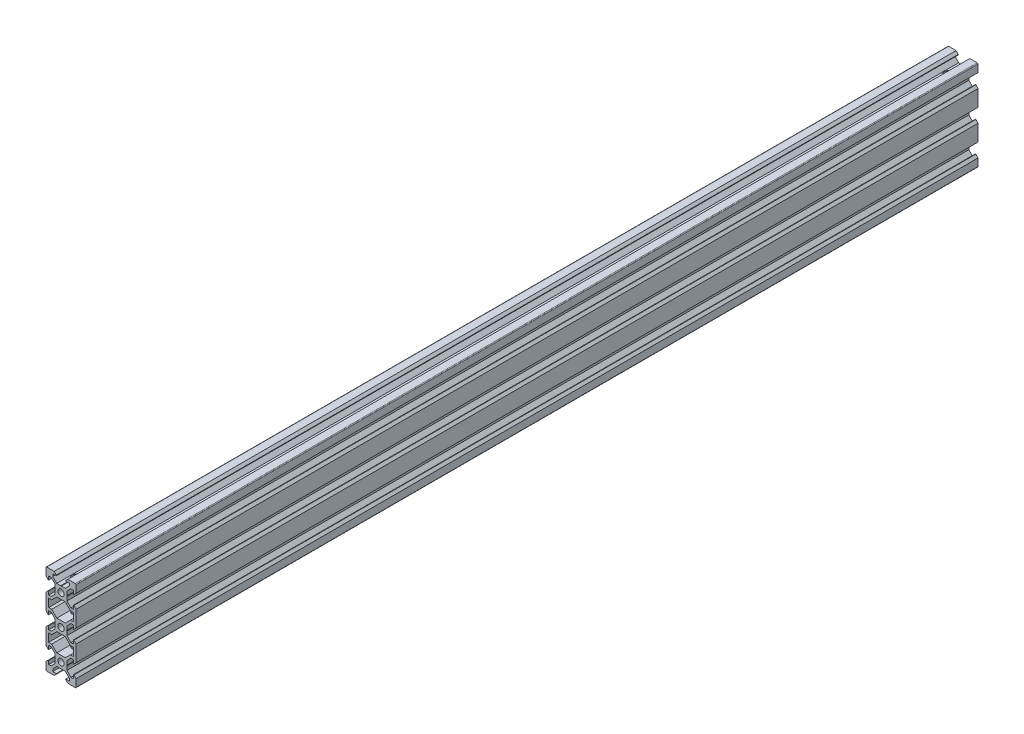
from build123d import *

# Parameters (mm, degrees)
SKETCH1_R               = 2.1
BOSS_EXTRUDE1_DEPTH     = 600
SKETCH2_R               = 2.55
CUT_EXTRUDE1_DEPTH      = 31
CUT_EXTRUDE1_DEPTH_BACK = 31


with BuildPart() as part:
    # Sketch1 → Boss-Extrude1 (new body)
    with BuildSketch(Plane.XY):
        with BuildLine():
            Line((4.58, -30), (9.5, -30))
            ThreePointArc((9.5, -30), (9.853553391, -29.853553391), (10, -29.5))
            Line((10, -29.5), (10, -24.58))
            Line((10, -24.58), (8.545, -23.125))
            Line((8.545, -23.125), (8.2, -23.125))
            Line((8.2, -23.125), (8.2, -25.5))
            Line((8.2, -25.5), (6.560660172, -25.5))
            Line((6.560660172, -25.5), (3.9, -22.839339828))
            Line((3.9, -22.839339828), (3.9, -20.21))
            Line((3.9, -20.21), (3.69, -20))
            Line((3.69, -20), (3.9, -19.79))
            Line((3.9, -19.79), (3.9, -17.160660172))
            Line((3.9, -17.160660172), (6.560660172, -14.5))
            Line((6.560660172, -14.5), (8.2, -14.5))
            Line((8.2, -14.5), (8.2, -16.875))
            Line((8.2, -16.875), (8.545, -16.875))
            Line((8.545, -16.875), (10, -15.42))
            Line((10, -15.42), (10, -4.58))
            Line((10, -4.58), (8.545, -3.125))
            Line((8.545, -3.125), (8.2, -3.125))
            Line((8.2, -3.125), (8.2, -5.5))
            Line((8.2, -5.5), (6.560660172, -5.5))
            Line((6.560660172, -5.5), (3.9, -2.839339828))
            Line((3.9, -2.839339828), (3.9, -0.21))
            Line((3.9, -0.21), (3.69, 0))
            Line((3.69, 0), (3.9, 0.21))
            Line((3.9, 0.21), (3.9, 2.839339828))
            Line((3.9, 2.839339828), (6.560660172, 5.5))
            Line((6.560660172, 5.5), (8.2, 5.5))
            Line((8.2, 5.5), (8.2, 3.125))
            Line((8.2, 3.125), (8.545, 3.125))
            Line((8.545, 3.125), (10, 4.58))
            Line((10, 4.58), (10, 15.42))
            Line((10, 15.42), (8.545, 16.875))
            Line((8.545, 16.875), (8.2, 16.875))
            Line((8.2, 16.875), (8.2, 14.5))
            Line((8.2, 14.5), (6.560660172, 14.5))
            Line((6.560660172, 14.5), (3.9, 17.160660172))
            Line((3.9, 17.160660172), (3.9, 19.79))
            Line((3.9, 19.79), (3.69, 20))
            Line((3.69, 20), (3.9, 20.21))
            Line((3.9, 20.21), (3.9, 22.839339828))
            Line((3.9, 22.839339828), (6.560660172, 25.5))
            Line((6.560660172, 25.5), (8.2, 25.5))
            Line((8.2, 25.5), (8.2, 23.125))
            Line((8.2, 23.125), (8.545, 23.125))
            Line((8.545, 23.125), (10, 24.58))
            Line((10, 24.58), (10, 29.5))
            ThreePointArc((10, 29.5), (9.853553391, 29.853553391), (9.5, 30))
            Line((9.5, 30), (4.58, 30))
            Line((4.58, 30), (3.125, 28.545))
            Line((3.125, 28.545), (3.125, 28.2))
            Line((3.125, 28.2), (5.5, 28.2))
            Line((5.5, 28.2), (5.5, 26.560660172))
            Line((5.5, 26.560660172), (2.839339828, 23.9))
            Line((2.839339828, 23.9), (0.21, 23.9))
            Line((0.21, 23.9), (0, 23.69))
            Line((0, 23.69), (-0.21, 23.9))
            Line((-0.21, 23.9), (-2.839339828, 23.9))
            Line((-2.839339828, 23.9), (-5.5, 26.560660172))
            Line((-5.5, 26.560660172), (-5.5, 28.2))
            Line((-5.5, 28.2), (-3.125, 28.2))
            Line((-3.125, 28.2), (-3.125, 28.545))
            Line((-3.125, 28.545), (-4.58, 30))
            Line((-4.58, 30), (-9.5, 30))
            ThreePointArc((-9.5, 30), (-9.853553391, 29.853553391), (-10, 29.5))
            Line((-10, 29.5), (-10, 24.58))
            Line((-10, 24.58), (-8.545, 23.125))
            Line((-8.545, 23.125), (-8.2, 23.125))
            Line((-8.2, 23.125), (-8.2, 25.5))
            Line((-8.2, 25.5), (-6.560660172, 25.5))
            Line((-6.560660172, 25.5), (-3.9, 22.839339828))
            Line((-3.9, 22.839339828), (-3.9, 20.21))
            Line((-3.9, 20.21), (-3.69, 20))
            Line((-3.69, 20), (-3.9, 19.79))
            Line((-3.9, 19.79), (-3.9, 17.160660172))
            Line((-3.9, 17.160660172), (-6.560660172, 14.5))
            Line((-6.560660172, 14.5), (-8.2, 14.5))
            Line((-8.2, 14.5), (-8.2, 16.875))
            Line((-8.2, 16.875), (-8.545, 16.875))
            Line((-8.545, 16.875), (-10, 15.42))
            Line((-10, 15.42), (-10, 4.58))
            Line((-10, 4.58), (-8.545, 3.125))
            Line((-8.545, 3.125), (-8.2, 3.125))
            Line((-8.2, 3.125), (-8.2, 5.5))
            Line((-8.2, 5.5), (-6.560660172, 5.5))
            Line((-6.560660172, 5.5), (-3.9, 2.839339828))
            Line((-3.9, 2.839339828), (-3.9, 0.21))
            Line((-3.9, 0.21), (-3.69, 0))
            Line((-3.69, 0), (-3.9, -0.21))
            Line((-3.9, -0.21), (-3.9, -2.839339828))
            Line((-3.9, -2.839339828), (-6.560660172, -5.5))
            Line((-6.560660172, -5.5), (-8.2, -5.5))
            Line((-8.2, -5.5), (-8.2, -3.125))
            Line((-8.2, -3.125), (-8.545, -3.125))
            Line((-8.545, -3.125), (-10, -4.58))
            Line((-10, -4.58), (-10, -15.42))
            Line((-10, -15.42), (-8.545, -16.875))
            Line((-8.545, -16.875), (-8.2, -16.875))
            Line((-8.2, -16.875), (-8.2, -14.5))
            Line((-8.2, -14.5), (-6.560660172, -14.5))
            Line((-6.560660172, -14.5), (-3.9, -17.160660172))
            Line((-3.9, -17.160660172), (-3.9, -19.79))
            Line((-3.9, -19.79), (-3.69, -20))
            Line((-3.69, -20), (-3.9, -20.21))
            Line((-3.9, -20.21), (-3.9, -22.839339828))
            Line((-3.9, -22.839339828), (-6.560660172, -25.5))
            Line((-6.560660172, -25.5), (-8.2, -25.5))
            Line((-8.2, -25.5), (-8.2, -23.125))
            Line((-8.2, -23.125), (-8.545, -23.125))
            Line((-8.545, -23.125), (-10, -24.58))
            Line((-10, -24.58), (-10, -29.5))
            ThreePointArc((-10, -29.5), (-9.853553391, -29.853553391), (-9.5, -30))
            Line((-9.5, -30), (-4.58, -30))
            Line((-4.58, -30), (-3.125, -28.545))
            Line((-3.125, -28.545), (-3.125, -28.2))
            Line((-3.125, -28.2), (-5.5, -28.2))
            Line((-5.5, -28.2), (-5.5, -26.560660172))
            Line((-5.5, -26.560660172), (-2.839339828, -23.9))
            Line((-2.839339828, -23.9), (-0.21, -23.9))
            Line((-0.21, -23.9), (0, -23.69))
            Line((0, -23.69), (0.21, -23.9))
            Line((0.21, -23.9), (2.839339828, -23.9))
            Line((2.839339828, -23.9), (5.5, -26.560660172))
            Line((5.5, -26.560660172), (5.5, -28.2))
            Line((5.5, -28.2), (3.125, -28.2))
            Line((3.125, -28.2), (3.125, -28.545))
            Line((3.125, -28.545), (4.58, -30))
        make_face()
        with Locations((0, -20)):
            Circle(SKETCH1_R, mode=Mode.SUBTRACT)
        Polygon((-6.239339828, -12.7), (-8.2, -12.7), (-8.2, -7.3), (-6.239339828, -7.3), (-2.839339828, -3.9), (2.839339828, -3.9), (6.239339828, -7.3), (8.2, -7.3), (8.2, -12.7), (6.239339828, -12.7), (2.839339828, -16.1), (-2.839339828, -16.1), align=None, mode=Mode.SUBTRACT)
        Polygon((-6.239339828, 7.3), (-8.2, 7.3), (-8.2, 12.7), (-6.239339828, 12.7), (-2.839339828, 16.1), (2.839339828, 16.1), (6.239339828, 12.7), (8.2, 12.7), (8.2, 7.3), (6.239339828, 7.3), (2.839339828, 3.9), (-2.839339828, 3.9), align=None, mode=Mode.SUBTRACT)
        with Locations((0, 20)):
            Circle(SKETCH1_R, mode=Mode.SUBTRACT)
        Circle(SKETCH1_R, mode=Mode.SUBTRACT)
    extrude(amount=BOSS_EXTRUDE1_DEPTH)

    # Sketch2 → Cut-Extrude1 (cut, two sides)
    with BuildSketch(Plane(origin=(0, 0, 0), x_dir=(1, 0, 0), z_dir=(0, 1, 0))) as cut_extrude1_sk:
        with Locations((0, -590)):
            Circle(SKETCH2_R)
        with Locations((0, -10)):
            Circle(SKETCH2_R)
    extrude(amount=CUT_EXTRUDE1_DEPTH, mode=Mode.SUBTRACT)
    extrude(cut_extrude1_sk.sketch, amount=-CUT_EXTRUDE1_DEPTH_BACK, mode=Mode.SUBTRACT)


solid = part.part
